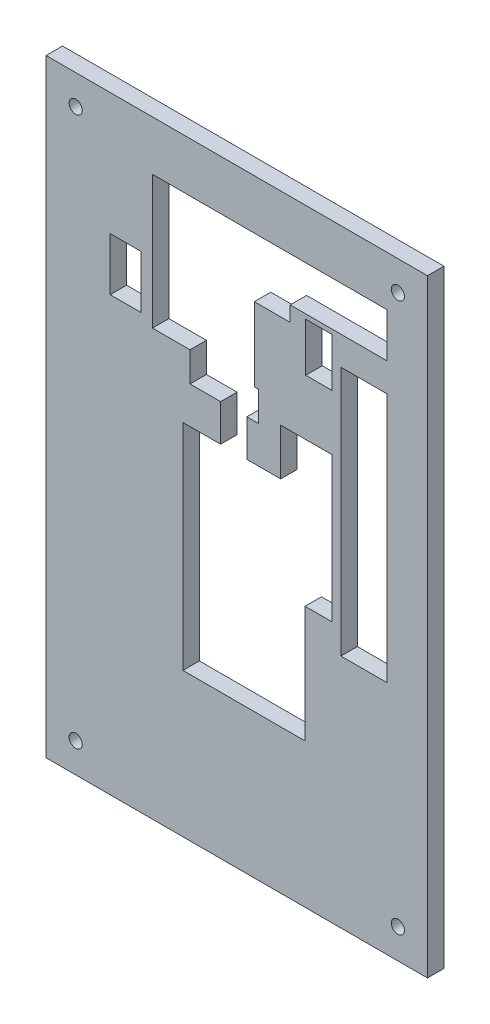
from build123d import *

# Parameters (mm, degrees)
SKETCH9_W           = 116
SKETCH9_H           = 185
SKETCH9_RX          = 2.0001
SKETCH9_RY          = 2
SKETCH9_W_2         = 14.0398
SKETCH9_H_2         = 76.0678
SKETCH9_W_3         = 8.0434
SKETCH9_H_3         = 14.7638
SKETCH9_W_4         = 9.3662
SKETCH9_H_4         = 16.0866
BOSS_EXTRUDE3_DEPTH = 5


with BuildPart() as part:
    # Sketch9 → Boss-Extrude3 (new body)
    with BuildSketch(Plane.XY):
        with Locations((75.4236, -0.0411)):
            Rectangle(SKETCH9_W, SKETCH9_H)
        with Locations((26.4237, 83.4589)):
            Ellipse(SKETCH9_RX, SKETCH9_RY, mode=Mode.SUBTRACT)
        with Locations((124.4237, 83.4589)):
            Ellipse(SKETCH9_RX, SKETCH9_RY, mode=Mode.SUBTRACT)
        with Locations((124.4237, -83.5411)):
            Ellipse(SKETCH9_RX, SKETCH9_RY, mode=Mode.SUBTRACT)
        with Locations((26.4237, -83.5411)):
            Ellipse(SKETCH9_RX, SKETCH9_RY, mode=Mode.SUBTRACT)
        with Locations((114.1237, 17.1372)):
            Rectangle(SKETCH9_W_2, SKETCH9_H_2, mode=Mode.SUBTRACT)
        with Locations((100.4225, 55.0986)):
            Rectangle(SKETCH9_W_3, SKETCH9_H_3, mode=Mode.SUBTRACT)
        Polygon((88.7925, 30.7834), (104.4559, 30.7834), (104.4559, 16.0196), (104.4559, -13.2439), (96.1886, -13.2439), (96.1886, -28.708), (96.1886, -48.708), (59.0411, -48.708), (59.0411, -28.708), (59.0411, 16.6008), (70.4989, 16.6008), (70.4989, 27.8192), (61.1857, 27.8192), (61.1857, 28.9577), (61.1857, 36.8241), (49.7696, 36.8241), (49.7696, 77.3371), (80.7576, 77.3371), (91.6664, 77.3371), (121.1436, 77.3371), (121.1436, 63.8829), (91.6664, 63.8829), (91.6664, 59.2791), (80.7576, 59.2791), (80.7576, 36.8241), (81.982, 36.8241), (81.982, 28.9577), (81.982, 27.8192), (78.4893, 27.8192), (78.4893, 16.6008), (88.7925, 16.6008), align=None, mode=Mode.SUBTRACT)
        with Locations((41.6049, 47.2397)):
            Rectangle(SKETCH9_W_4, SKETCH9_H_4, mode=Mode.SUBTRACT)
    extrude(amount=BOSS_EXTRUDE3_DEPTH)


solid = part.part
